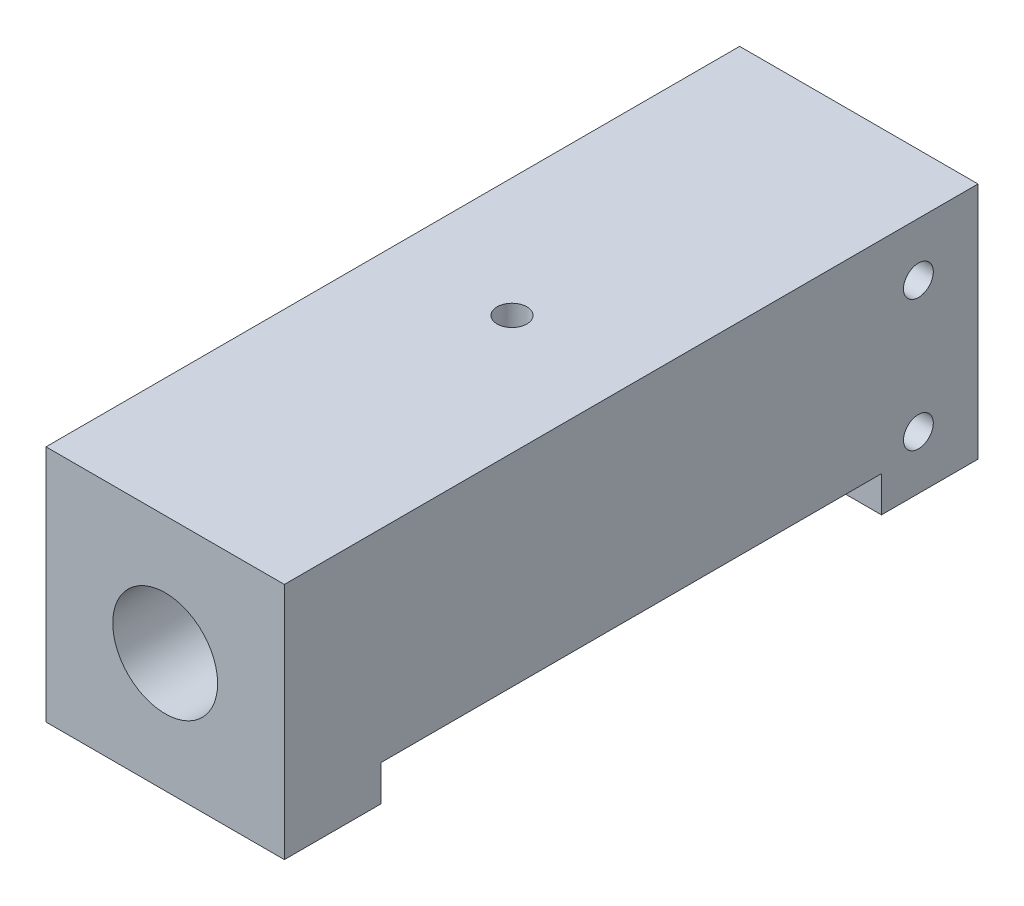
from build123d import *

# Parameters (mm, degrees)
SCHIZZO1_W                   = 20
SCHIZZO1_H                   = 20
ESTRUSIONE_ESTRUSIONE1_DEPTH = 58.2
SCHIZZO2_R                   = 2.05
TAGLIO_ESTRUSIONE1_DEPTH     = 60.893572276
FORO_FILETTATO_G1_8_1_D      = 8.8
FORO_FILETTATO_G1_8_1_DEPTH  = 10
FORO_FILETTATO_G1_8_1_TIP    = 2.643786724
M3_TAPPED_HOLE2_D            = 2.5
M3_TAPPED_HOLE2_DEPTH        = 5
M3_TAPPED_HOLE2_TIP          = 0.751075774
M3_TAPPED_HOLE3_REACH        = 60.911
M3_TAPPED_HOLE3_BORE_R       = 1.25
SKETCH1_W                    = 36.2
SKETCH1_H                    = 6
BOSS_EXTRUDE1_DEPTH          = 4.9
CUT_EXTRUDE1_DEPTH           = 65.087830449
M3_TAPPED_HOLE4_D            = 2.5
M3_TAPPED_HOLE4_DEPTH        = 20
M3_TAPPED_HOLE4_TIP          = 0.751075774


with BuildPart() as part:
    # Schizzo1 → Estrusione-Estrusione1 (new body)
    with BuildSketch(Plane.XY):
        Rectangle(SCHIZZO1_W, SCHIZZO1_H)
    extrude(amount=-ESTRUSIONE_ESTRUSIONE1_DEPTH)

    # Schizzo2 → Taglio-Estrusione1 (cut, through all)
    with BuildSketch(Plane(origin=(0, 0, -58.2), x_dir=(-1, 0, 0), z_dir=(0, 0, -1))):
        Circle(SCHIZZO2_R)
    extrude(amount=-TAGLIO_ESTRUSIONE1_DEPTH, mode=Mode.SUBTRACT)

    # Foro filettato G1/8-1
    with Locations(Plane.XY):
        with Locations((0, 0)):
            Hole(FORO_FILETTATO_G1_8_1_D / 2, depth=FORO_FILETTATO_G1_8_1_DEPTH)
            with Locations((0, 0, -(FORO_FILETTATO_G1_8_1_DEPTH + FORO_FILETTATO_G1_8_1_TIP / 2))):  # 118° drill point
                Cone(0, FORO_FILETTATO_G1_8_1_D / 2, FORO_FILETTATO_G1_8_1_TIP, mode=Mode.SUBTRACT)

    # M3 Tapped Hole2
    with Locations(Plane(origin=(0, 10, -29.1), x_dir=(1, 0, 0), z_dir=(0, 1, 0))):
        with Locations((0, 0)):
            Hole(M3_TAPPED_HOLE2_D / 2, depth=M3_TAPPED_HOLE2_DEPTH)
            with Locations((0, 0, -(M3_TAPPED_HOLE2_DEPTH + M3_TAPPED_HOLE2_TIP / 2))):  # 118° drill point
                Cone(0, M3_TAPPED_HOLE2_D / 2, M3_TAPPED_HOLE2_TIP, mode=Mode.SUBTRACT)

    # Schizzo14 → Foro Ø16.0 (16)-1 (revolve, cut)
    with BuildSketch(Plane(origin=(0, 0, -58.2), x_dir=(0, 1, 0), z_dir=(1, 0, 0))):
        Polygon((0, 0), (0, 16.806884952), (8, 12), (8, 0), align=None)
    revolve(axis=Axis((0, 0, -64.55), (0, 0, 1)), mode=Mode.SUBTRACT)

    # M3 Tapped Hole3 bore (on position points) → M3 Tapped Hole3 (cut, up to next)
    with BuildSketch(Plane(origin=(10, 5.5, -53.2), x_dir=(0, 0, 1), z_dir=(1, 0, 0)), mode=Mode.PRIVATE) as m3_tapped_hole3_sk1:
        Circle(M3_TAPPED_HOLE3_BORE_R)
    m3_tapped_hole3_tool1 = extrude(m3_tapped_hole3_sk1.sketch, amount=-M3_TAPPED_HOLE3_REACH, mode=Mode.PRIVATE) & part.part
    # M3 Tapped Hole3 bore (on position points) → M3 Tapped Hole3 (cut, up to next)
    with BuildSketch(Plane(origin=(10, 5.5, -53.2), x_dir=(0, 0, 1), z_dir=(1, 0, 0)), mode=Mode.PRIVATE) as m3_tapped_hole3_sk2:
        with Locations((0, 11)):
            Circle(M3_TAPPED_HOLE3_BORE_R)
    m3_tapped_hole3_tool2 = extrude(m3_tapped_hole3_sk2.sketch, amount=-M3_TAPPED_HOLE3_REACH, mode=Mode.PRIVATE) & part.part
    add(m3_tapped_hole3_tool1.solids().sort_by_distance((10, 5.5, -53.2))[0], mode=Mode.SUBTRACT)
    add(m3_tapped_hole3_tool2.solids().sort_by_distance((10, -5.5, -53.2))[0], mode=Mode.SUBTRACT)

    # Sketch1 → Boss-Extrude1 (add)
    with BuildSketch(Plane.ZY.offset(10)):
        with Locations((-40.1, 0)):
            Rectangle(SKETCH1_W, SKETCH1_H)
    extrude(amount=BOSS_EXTRUDE1_DEPTH)

    # Sketch2 → Cut-Extrude1 (cut, through all)
    with BuildSketch(Plane(origin=(10, 0, 0), x_dir=(0, 0, -1), z_dir=(1, 0, 0))):
        Polygon((50.1, -10), (34.1, -10), (8.1, -10), (8.1, -7), (34.1, -7), (50.1, -7), align=None)
    extrude(amount=-CUT_EXTRUDE1_DEPTH, mode=Mode.SUBTRACT)

    # M3 Tapped Hole4
    with Locations(Plane.XY.offset(-22)):
        with Locations((-13, 0)):
            Hole(M3_TAPPED_HOLE4_D / 2, depth=M3_TAPPED_HOLE4_DEPTH)
            with Locations((0, 0, -(M3_TAPPED_HOLE4_DEPTH + M3_TAPPED_HOLE4_TIP / 2))):  # 118° drill point
                Cone(0, M3_TAPPED_HOLE4_D / 2, M3_TAPPED_HOLE4_TIP, mode=Mode.SUBTRACT)


solid = part.part
